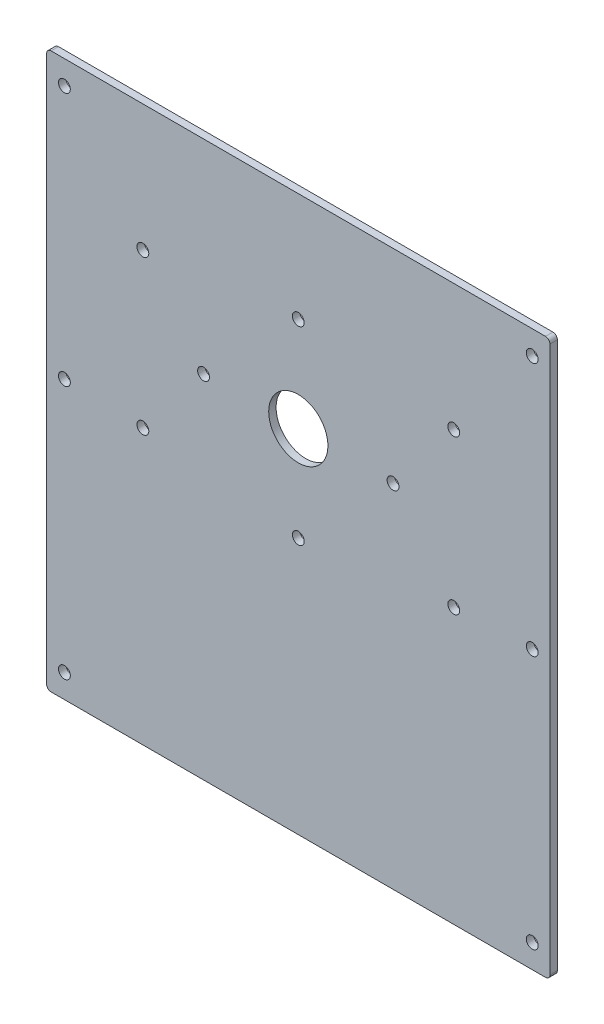
from build123d import *

# Parameters (mm, degrees)
SKETCH1_R           = 20
SKETCH1_R_2         = 4
BOSS_EXTRUDE1_DEPTH = 5


with BuildPart() as part:
    # Sketch1 → Boss-Extrude1 (new body)
    with BuildSketch(Plane.XY.offset(5)):
        with BuildLine():
            Line((-170, 184.5), (-170, -184.5))
            ThreePointArc((-170, -184.5), (-169.121320344, -186.621320344), (-167, -187.5))
            Line((-167, -187.5), (167, -187.5))
            ThreePointArc((167, -187.5), (169.121320344, -186.621320344), (170, -184.5))
            Line((170, -184.5), (170, 184.5))
            ThreePointArc((170, 184.5), (169.121320344, 186.621320344), (167, 187.5))
            Line((167, 187.5), (-167, 187.5))
            ThreePointArc((-167, 187.5), (-169.121320344, 186.621320344), (-170, 184.5))
        make_face()
        with Locations((0, 50)):
            Circle(SKETCH1_R, mode=Mode.SUBTRACT)
        with Locations((-64, 50)):
            Circle(SKETCH1_R_2, mode=Mode.SUBTRACT)
        with Locations((0, 114)):
            Circle(SKETCH1_R_2, mode=Mode.SUBTRACT)
        with Locations((64, 50)):
            Circle(SKETCH1_R_2, mode=Mode.SUBTRACT)
        with Locations((0, -14)):
            Circle(SKETCH1_R_2, mode=Mode.SUBTRACT)
        with Locations((158, 0)):
            Circle(SKETCH1_R_2, mode=Mode.SUBTRACT)
        with Locations((-158, 0)):
            Circle(SKETCH1_R_2, mode=Mode.SUBTRACT)
        with Locations((158, 171.5)):
            Circle(SKETCH1_R_2, mode=Mode.SUBTRACT)
        with Locations((-158, 171.5)):
            Circle(SKETCH1_R_2, mode=Mode.SUBTRACT)
        with Locations((-158, -171.5)):
            Circle(SKETCH1_R_2, mode=Mode.SUBTRACT)
        with Locations((158, -171.5)):
            Circle(SKETCH1_R_2, mode=Mode.SUBTRACT)
        with Locations((-105, 102)):
            Circle(SKETCH1_R_2, mode=Mode.SUBTRACT)
        with Locations((-105, -2)):
            Circle(SKETCH1_R_2, mode=Mode.SUBTRACT)
        with Locations((105, 102)):
            Circle(SKETCH1_R_2, mode=Mode.SUBTRACT)
        with Locations((105, -2)):
            Circle(SKETCH1_R_2, mode=Mode.SUBTRACT)
    extrude(amount=-BOSS_EXTRUDE1_DEPTH)


solid = part.part
